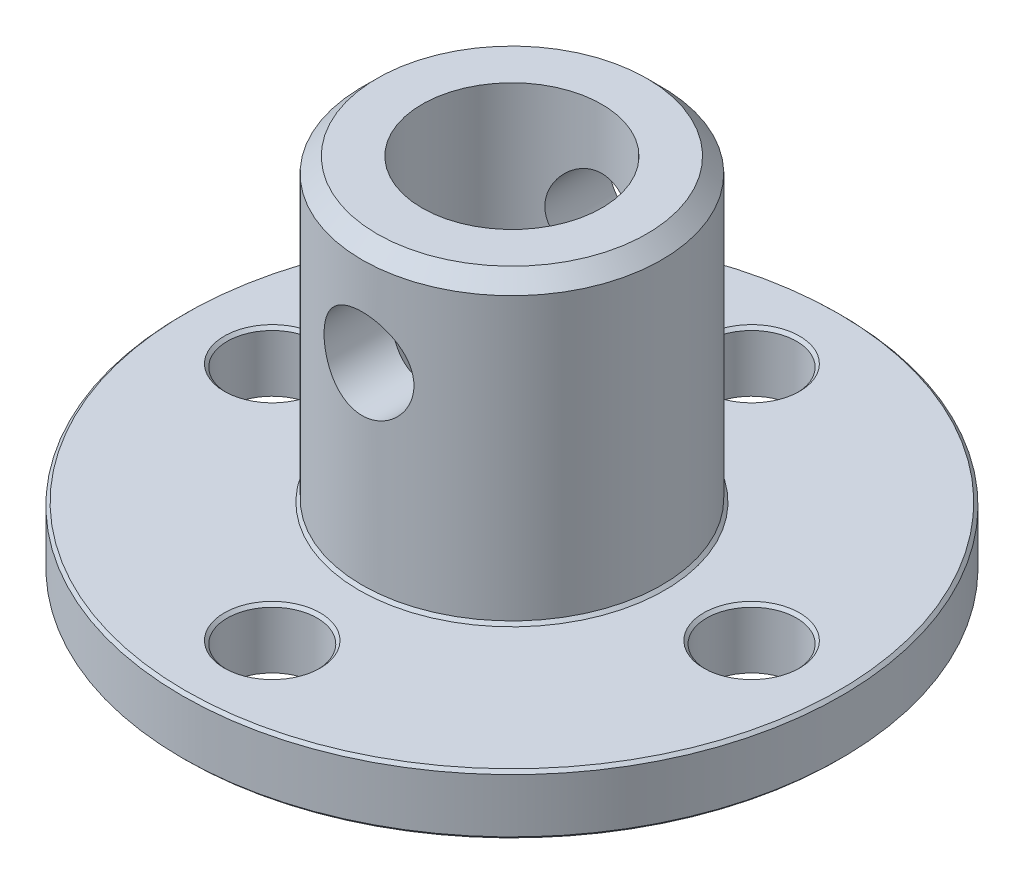
from build123d import *

# Parameters (mm, degrees)
SKETCH1_R           = 11
SKETCH1_R_2         = 3
SKETCH1_R_3         = 1.5
BOSS_EXTRUDE1_DEPTH = 2
SKETCH2_R           = 5
SKETCH2_R_2         = 3
BOSS_EXTRUDE2_DEPTH = 10
CHAMFER1_SIZE       = 0.5
CHAMFER2_SIZE       = 0.1
CUT_EXTRUDE1_DEPTH  = 10


with BuildPart() as part:
    # Sketch1 → Boss-Extrude1 (new body)
    with BuildSketch(Plane(origin=(0, 0, 0), x_dir=(1, 0, 0), z_dir=(0, 1, 0))):
        Circle(SKETCH1_R)
        Circle(SKETCH1_R_2, mode=Mode.SUBTRACT)
        with Locations((0, 8)):
            Circle(SKETCH1_R_3, mode=Mode.SUBTRACT)
        with Locations((8, 0)):
            Circle(SKETCH1_R_3, mode=Mode.SUBTRACT)
        with Locations((0, -8)):
            Circle(SKETCH1_R_3, mode=Mode.SUBTRACT)
        with Locations((-8, 0)):
            Circle(SKETCH1_R_3, mode=Mode.SUBTRACT)
    extrude(amount=BOSS_EXTRUDE1_DEPTH)

    # Sketch2 → Boss-Extrude2 (add)
    with BuildSketch(Plane(origin=(0, 2, 0), x_dir=(1, 0, 0), z_dir=(0, 1, 0))):
        Circle(SKETCH2_R)
        Circle(SKETCH2_R_2, mode=Mode.SUBTRACT)
    extrude(amount=BOSS_EXTRUDE2_DEPTH)

    # Chamfer1
    chamfer1_edges = [part.edges().sort_by_distance(p)[0] for p in [
        (-5, 12, 0),
    ]]
    chamfer(chamfer1_edges, length=CHAMFER1_SIZE)

    # Chamfer2
    chamfer2_edges = [part.edges().sort_by_distance(p)[0] for p in [
        (-1.5, 2, -8),
        (-1.5, 2, 8),
        (-5, 2, 0),
        (-9.5, 2, 0),
        (6.5, 2, 0),
        (-11, 2, 0),
        (-11, 0, 0),
    ]]
    chamfer(chamfer2_edges, length=CHAMFER2_SIZE)

    # Sketch3 → Cut-Extrude1 (cut)
    with BuildSketch(Plane.XY.offset(5)):
        with BuildLine():
            ThreePointArc((0, 10), (-1.5, 8.5), (0, 7))
            Line((0, 7), (0, 10))
        make_face()
        with BuildLine():
            Line((0, 10), (0, 7))
            ThreePointArc((0, 7), (1.060660172, 7.439339828), (1.5, 8.5))
            ThreePointArc((1.5, 8.5), (1.060660172, 9.560660172), (0, 10))
        make_face()
    extrude(amount=-CUT_EXTRUDE1_DEPTH, mode=Mode.SUBTRACT)


solid = part.part
